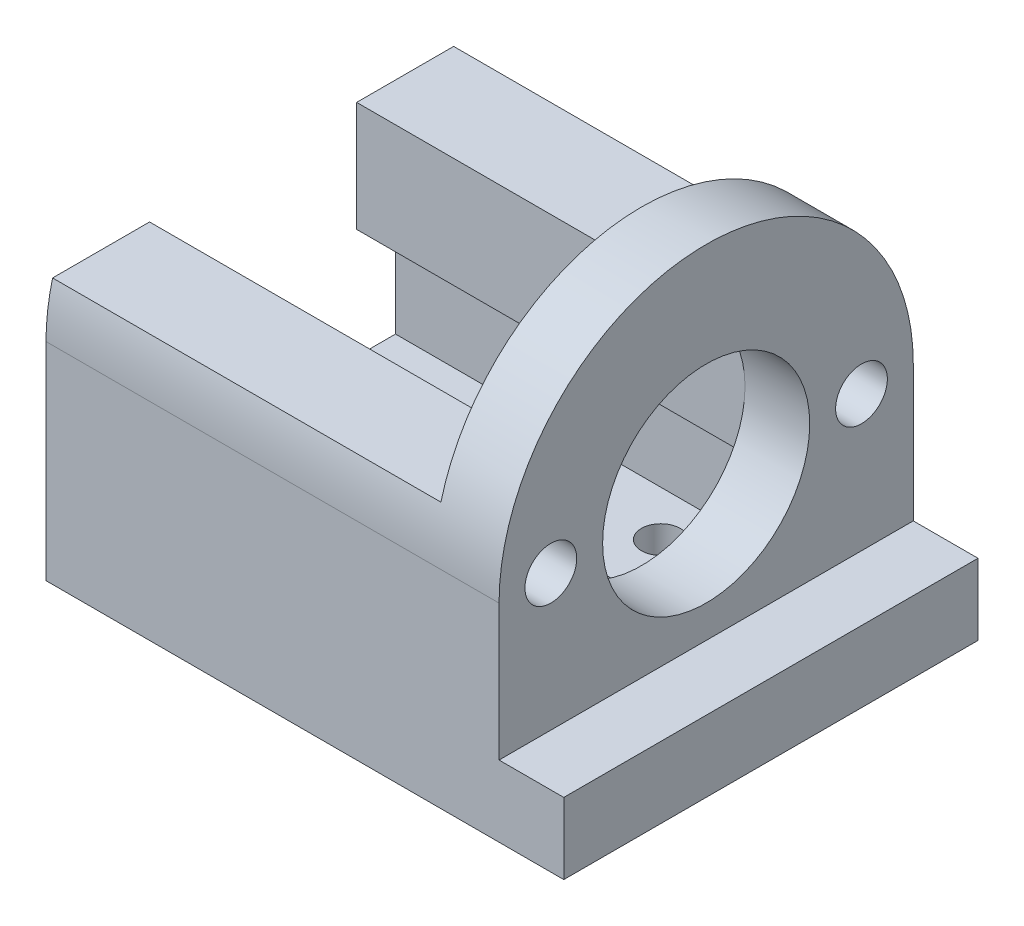
from build123d import *

# Parameters (mm, degrees)
SKETCH_1_R          = 8
SKETCH_1_R_2        = 2
EXTRUDE_1_DEPTH     = 5
SKETCH_3_W          = 32
SKETCH_3_H          = 5.5
EXTRUDE_3_DEPTH     = 5
EXTRUDE_4_DEPTH     = 30
SKETCH_6_R          = 1.5
CUT_EXTRUDE_1_DEPTH = 20
SKETCH_7_W          = 3
SKETCH_7_H          = 8.5
CUT_EXTRUDE_5_DEPTH = 30


with BuildPart() as part:
    # 草图1 → 凸台-拉伸1 (new body)
    with BuildSketch(Plane(origin=(0, 0, 0), x_dir=(0, 0, -1), z_dir=(1, 0, 0))):
        with BuildLine():
            Line((-16, 0), (-16, -16))
            Line((-16, -16), (16, -16))
            Line((16, -16), (16, 0))
            ThreePointArc((16, 0), (0, 16), (-16, 0))
        make_face()
        Circle(SKETCH_1_R, mode=Mode.SUBTRACT)
        with Locations((-12, 0)):
            Circle(SKETCH_1_R_2, mode=Mode.SUBTRACT)
        with Locations((12, 0)):
            Circle(SKETCH_1_R_2, mode=Mode.SUBTRACT)
    extrude(amount=EXTRUDE_1_DEPTH)

    # 草图3 → 凸台-拉伸3 (add)
    with BuildSketch(Plane(origin=(5, 0, 0), x_dir=(0, 0, -1), z_dir=(1, 0, 0))):
        with Locations((0, -13.25)):
            Rectangle(SKETCH_3_W, SKETCH_3_H)
    extrude(amount=EXTRUDE_3_DEPTH)

    # 草图4 → 凸台-拉伸4 (add)
    with BuildSketch(Plane.ZY):
        with BuildLine():
            Line((-8, 4), (-15.491933385, 4))
            ThreePointArc((-15.491933385, 4), (-15.87247514, 2.01606868), (-16, 0))
            Line((-16, 0), (-16, -16))
            Line((-16, -16), (-3, -16))
            Line((-3, -16), (-3, -13))
            Line((-3, -13), (-8, -13))
            Line((-8, -13), (-8, 4))
        make_face()
        with BuildLine():
            Line((3, -13), (3, -16))
            Line((3, -16), (16, -16))
            Line((16, -16), (16, 0))
            ThreePointArc((16, 0), (15.87247514, 2.01606868), (15.491933385, 4))
            Line((15.491933385, 4), (8, 4))
            Line((8, 4), (8, -13))
            Line((8, -13), (3, -13))
        make_face()
    extrude(amount=EXTRUDE_4_DEPTH)

    # 草图6 → 切除-拉伸1 (cut)
    with BuildSketch(Plane(origin=(0, -13, 0), x_dir=(1, 0, 0), z_dir=(0, 1, 0))):
        with Locations((-6, -7.5)):
            Circle(SKETCH_6_R)
        with Locations((-6, 7.5)):
            Circle(SKETCH_6_R)
        with Locations((-26, 7.5)):
            Circle(SKETCH_6_R)
        with Locations((-26, -7.5)):
            Circle(SKETCH_6_R)
    extrude(amount=-CUT_EXTRUDE_1_DEPTH, mode=Mode.SUBTRACT)

    # 草图7 → 切除-拉伸5 (cut)
    with BuildSketch(Plane.ZY.offset(30)):
        with Locations((-9.5, -8.75)):
            Rectangle(SKETCH_7_W, SKETCH_7_H)
        with Locations((9.5, -8.75)):
            Rectangle(SKETCH_7_W, SKETCH_7_H)
    extrude(amount=-CUT_EXTRUDE_5_DEPTH, mode=Mode.SUBTRACT)


solid = part.part
